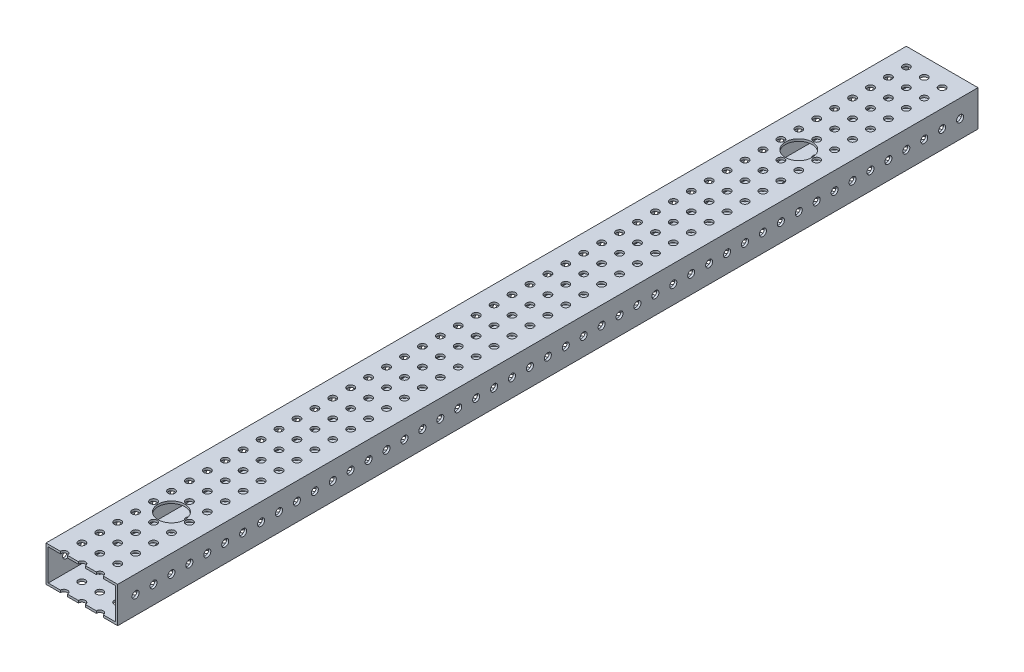
from build123d import *

# Parameters (mm, degrees)
SKETCH1_W           = 50.8
SKETCH1_H           = 25.4
SKETCH1_W_2         = 47.625
SKETCH1_H_2         = 22.225
BOSS_EXTRUDE1_DEPTH = 609.6
SKETCH2_R           = 2.4892
CUT_EXTRUDE1_DEPTH  = 51.8
SKETCH4_R           = 2.4892
CUT_EXTRUDE3_DEPTH  = 26.4
SKETCH3_R           = 9.525
CUT_EXTRUDE2_DEPTH  = 26.4


with BuildPart() as part:
    # Sketch1 → Boss-Extrude1 (new body)
    with BuildSketch(Plane.XY):
        with Locations((25.4, 12.7)):
            Rectangle(SKETCH1_W, SKETCH1_H)
        with Locations((25.4, 12.7)):
            Rectangle(SKETCH1_W_2, SKETCH1_H_2, mode=Mode.SUBTRACT)
    extrude(amount=BOSS_EXTRUDE1_DEPTH)

    # Sketch2 → Cut-Extrude1 (cut, through all)
    with BuildSketch(Plane(origin=(50.8, 0, 0), x_dir=(0, 0, -1), z_dir=(1, 0, 0))):
        with Locations((-596.9, 12.7)):
            Circle(SKETCH2_R)
        with Locations((-584.2, 12.7)):
            Circle(SKETCH2_R)
        with Locations((-571.5, 12.7)):
            Circle(SKETCH2_R)
        with Locations((-558.8, 12.7)):
            Circle(SKETCH2_R)
        with Locations((-546.1, 12.7)):
            Circle(SKETCH2_R)
        with Locations((-533.4, 12.7)):
            Circle(SKETCH2_R)
        with Locations((-520.7, 12.7)):
            Circle(SKETCH2_R)
        with Locations((-508, 12.7)):
            Circle(SKETCH2_R)
        with Locations((-495.3, 12.7)):
            Circle(SKETCH2_R)
        with Locations((-482.6, 12.7)):
            Circle(SKETCH2_R)
        with Locations((-469.9, 12.7)):
            Circle(SKETCH2_R)
        with Locations((-457.2, 12.7)):
            Circle(SKETCH2_R)
        with Locations((-444.5, 12.7)):
            Circle(SKETCH2_R)
        with Locations((-431.8, 12.7)):
            Circle(SKETCH2_R)
        with Locations((-419.1, 12.7)):
            Circle(SKETCH2_R)
        with Locations((-406.4, 12.7)):
            Circle(SKETCH2_R)
        with Locations((-393.7, 12.7)):
            Circle(SKETCH2_R)
        with Locations((-381, 12.7)):
            Circle(SKETCH2_R)
        with Locations((-368.3, 12.7)):
            Circle(SKETCH2_R)
        with Locations((-355.6, 12.7)):
            Circle(SKETCH2_R)
        with Locations((-342.9, 12.7)):
            Circle(SKETCH2_R)
        with Locations((-330.2, 12.7)):
            Circle(SKETCH2_R)
        with Locations((-317.5, 12.7)):
            Circle(SKETCH2_R)
        with Locations((-304.8, 12.7)):
            Circle(SKETCH2_R)
        with Locations((-292.1, 12.7)):
            Circle(SKETCH2_R)
        with Locations((-279.4, 12.7)):
            Circle(SKETCH2_R)
        with Locations((-266.7, 12.7)):
            Circle(SKETCH2_R)
        with Locations((-254, 12.7)):
            Circle(SKETCH2_R)
        with Locations((-241.3, 12.7)):
            Circle(SKETCH2_R)
        with Locations((-228.6, 12.7)):
            Circle(SKETCH2_R)
        with Locations((-215.9, 12.7)):
            Circle(SKETCH2_R)
        with Locations((-203.2, 12.7)):
            Circle(SKETCH2_R)
        with Locations((-190.5, 12.7)):
            Circle(SKETCH2_R)
        with Locations((-177.8, 12.7)):
            Circle(SKETCH2_R)
        with Locations((-165.1, 12.7)):
            Circle(SKETCH2_R)
        with Locations((-152.4, 12.7)):
            Circle(SKETCH2_R)
        with Locations((-139.7, 12.7)):
            Circle(SKETCH2_R)
        with Locations((-127, 12.7)):
            Circle(SKETCH2_R)
        with Locations((-114.3, 12.7)):
            Circle(SKETCH2_R)
        with Locations((-101.6, 12.7)):
            Circle(SKETCH2_R)
        with Locations((-88.9, 12.7)):
            Circle(SKETCH2_R)
        with Locations((-76.2, 12.7)):
            Circle(SKETCH2_R)
        with Locations((-63.5, 12.7)):
            Circle(SKETCH2_R)
        with Locations((-50.8, 12.7)):
            Circle(SKETCH2_R)
        with Locations((-38.1, 12.7)):
            Circle(SKETCH2_R)
        with Locations((-25.4, 12.7)):
            Circle(SKETCH2_R)
        with Locations((-12.7, 12.7)):
            Circle(SKETCH2_R)
    extrude(amount=-CUT_EXTRUDE1_DEPTH, mode=Mode.SUBTRACT)

    # Sketch4 → Cut-Extrude3 (cut, through all)
    with BuildSketch(Plane(origin=(0, 25.4, 0), x_dir=(1, 0, 0), z_dir=(0, 1, 0))):
        with Locations((12.7, -12.7)):
            Circle(SKETCH4_R)
        with Locations((25.4, -12.7)):
            Circle(SKETCH4_R)
        with Locations((38.1, -12.7)):
            Circle(SKETCH4_R)
        with Locations((25.4, -25.4)):
            Circle(SKETCH4_R)
        with Locations((38.1, -25.4)):
            Circle(SKETCH4_R)
        with Locations((25.4, -38.1)):
            Circle(SKETCH4_R)
        with Locations((38.1, -38.1)):
            Circle(SKETCH4_R)
        with Locations((25.4, -50.8)):
            Circle(SKETCH4_R)
        with Locations((38.1, -50.8)):
            Circle(SKETCH4_R)
        with Locations((25.4, -63.5)):
            Circle(SKETCH4_R)
        with Locations((38.1, -63.5)):
            Circle(SKETCH4_R)
        with Locations((25.4, -76.2)):
            Circle(SKETCH4_R)
        with Locations((38.1, -76.2)):
            Circle(SKETCH4_R)
        with Locations((25.4, -88.9)):
            Circle(SKETCH4_R)
        with Locations((38.1, -88.9)):
            Circle(SKETCH4_R)
        with Locations((25.4, -101.6)):
            Circle(SKETCH4_R)
        with Locations((38.1, -101.6)):
            Circle(SKETCH4_R)
        with Locations((25.4, -114.3)):
            Circle(SKETCH4_R)
        with Locations((38.1, -114.3)):
            Circle(SKETCH4_R)
        with Locations((25.4, -127)):
            Circle(SKETCH4_R)
        with Locations((38.1, -127)):
            Circle(SKETCH4_R)
        with Locations((25.4, -139.7)):
            Circle(SKETCH4_R)
        with Locations((38.1, -139.7)):
            Circle(SKETCH4_R)
        with Locations((25.4, -152.4)):
            Circle(SKETCH4_R)
        with Locations((38.1, -152.4)):
            Circle(SKETCH4_R)
        with Locations((25.4, -165.1)):
            Circle(SKETCH4_R)
        with Locations((38.1, -165.1)):
            Circle(SKETCH4_R)
        with Locations((25.4, -177.8)):
            Circle(SKETCH4_R)
        with Locations((38.1, -177.8)):
            Circle(SKETCH4_R)
        with Locations((25.4, -190.5)):
            Circle(SKETCH4_R)
        with Locations((38.1, -190.5)):
            Circle(SKETCH4_R)
        with Locations((25.4, -203.2)):
            Circle(SKETCH4_R)
        with Locations((38.1, -203.2)):
            Circle(SKETCH4_R)
        with Locations((25.4, -215.9)):
            Circle(SKETCH4_R)
        with Locations((38.1, -215.9)):
            Circle(SKETCH4_R)
        with Locations((25.4, -228.6)):
            Circle(SKETCH4_R)
        with Locations((38.1, -228.6)):
            Circle(SKETCH4_R)
        with Locations((25.4, -241.3)):
            Circle(SKETCH4_R)
        with Locations((38.1, -241.3)):
            Circle(SKETCH4_R)
        with Locations((25.4, -254)):
            Circle(SKETCH4_R)
        with Locations((38.1, -254)):
            Circle(SKETCH4_R)
        with Locations((25.4, -266.7)):
            Circle(SKETCH4_R)
        with Locations((38.1, -266.7)):
            Circle(SKETCH4_R)
        with Locations((25.4, -279.4)):
            Circle(SKETCH4_R)
        with Locations((38.1, -279.4)):
            Circle(SKETCH4_R)
        with Locations((25.4, -292.1)):
            Circle(SKETCH4_R)
        with Locations((38.1, -292.1)):
            Circle(SKETCH4_R)
        with Locations((25.4, -304.8)):
            Circle(SKETCH4_R)
        with Locations((38.1, -304.8)):
            Circle(SKETCH4_R)
        with Locations((25.4, -317.5)):
            Circle(SKETCH4_R)
        with Locations((38.1, -317.5)):
            Circle(SKETCH4_R)
        with Locations((25.4, -330.2)):
            Circle(SKETCH4_R)
        with Locations((38.1, -330.2)):
            Circle(SKETCH4_R)
        with Locations((25.4, -342.9)):
            Circle(SKETCH4_R)
        with Locations((38.1, -342.9)):
            Circle(SKETCH4_R)
        with Locations((25.4, -355.6)):
            Circle(SKETCH4_R)
        with Locations((38.1, -355.6)):
            Circle(SKETCH4_R)
        with Locations((25.4, -368.3)):
            Circle(SKETCH4_R)
        with Locations((38.1, -368.3)):
            Circle(SKETCH4_R)
        with Locations((25.4, -381)):
            Circle(SKETCH4_R)
        with Locations((38.1, -381)):
            Circle(SKETCH4_R)
        with Locations((25.4, -393.7)):
            Circle(SKETCH4_R)
        with Locations((38.1, -393.7)):
            Circle(SKETCH4_R)
        with Locations((25.4, -406.4)):
            Circle(SKETCH4_R)
        with Locations((38.1, -406.4)):
            Circle(SKETCH4_R)
        with Locations((25.4, -419.1)):
            Circle(SKETCH4_R)
        with Locations((38.1, -419.1)):
            Circle(SKETCH4_R)
        with Locations((25.4, -431.8)):
            Circle(SKETCH4_R)
        with Locations((38.1, -431.8)):
            Circle(SKETCH4_R)
        with Locations((25.4, -444.5)):
            Circle(SKETCH4_R)
        with Locations((38.1, -444.5)):
            Circle(SKETCH4_R)
        with Locations((25.4, -457.2)):
            Circle(SKETCH4_R)
        with Locations((38.1, -457.2)):
            Circle(SKETCH4_R)
        with Locations((25.4, -469.9)):
            Circle(SKETCH4_R)
        with Locations((38.1, -469.9)):
            Circle(SKETCH4_R)
        with Locations((25.4, -482.6)):
            Circle(SKETCH4_R)
        with Locations((38.1, -482.6)):
            Circle(SKETCH4_R)
        with Locations((25.4, -495.3)):
            Circle(SKETCH4_R)
        with Locations((38.1, -495.3)):
            Circle(SKETCH4_R)
        with Locations((25.4, -508)):
            Circle(SKETCH4_R)
        with Locations((38.1, -508)):
            Circle(SKETCH4_R)
        with Locations((25.4, -520.7)):
            Circle(SKETCH4_R)
        with Locations((38.1, -520.7)):
            Circle(SKETCH4_R)
        with Locations((25.4, -533.4)):
            Circle(SKETCH4_R)
        with Locations((38.1, -533.4)):
            Circle(SKETCH4_R)
        with Locations((25.4, -546.1)):
            Circle(SKETCH4_R)
        with Locations((38.1, -546.1)):
            Circle(SKETCH4_R)
        with Locations((25.4, -558.8)):
            Circle(SKETCH4_R)
        with Locations((38.1, -558.8)):
            Circle(SKETCH4_R)
        with Locations((25.4, -571.5)):
            Circle(SKETCH4_R)
        with Locations((38.1, -571.5)):
            Circle(SKETCH4_R)
        with Locations((25.4, -584.2)):
            Circle(SKETCH4_R)
        with Locations((38.1, -584.2)):
            Circle(SKETCH4_R)
        with Locations((25.4, -596.9)):
            Circle(SKETCH4_R)
        with Locations((38.1, -596.9)):
            Circle(SKETCH4_R)
        with Locations((25.4, -609.6)):
            Circle(SKETCH4_R)
        with Locations((38.1, -609.6)):
            Circle(SKETCH4_R)
        with Locations((12.7, -25.4)):
            Circle(SKETCH4_R)
        with Locations((12.7, -38.1)):
            Circle(SKETCH4_R)
        with Locations((12.7, -50.8)):
            Circle(SKETCH4_R)
        with Locations((12.7, -63.5)):
            Circle(SKETCH4_R)
        with Locations((12.7, -76.2)):
            Circle(SKETCH4_R)
        with Locations((12.7, -88.9)):
            Circle(SKETCH4_R)
        with Locations((12.7, -101.6)):
            Circle(SKETCH4_R)
        with Locations((12.7, -114.3)):
            Circle(SKETCH4_R)
        with Locations((12.7, -127)):
            Circle(SKETCH4_R)
        with Locations((12.7, -139.7)):
            Circle(SKETCH4_R)
        with Locations((12.7, -152.4)):
            Circle(SKETCH4_R)
        with Locations((12.7, -165.1)):
            Circle(SKETCH4_R)
        with Locations((12.7, -177.8)):
            Circle(SKETCH4_R)
        with Locations((12.7, -190.5)):
            Circle(SKETCH4_R)
        with Locations((12.7, -203.2)):
            Circle(SKETCH4_R)
        with Locations((12.7, -215.9)):
            Circle(SKETCH4_R)
        with Locations((12.7, -228.6)):
            Circle(SKETCH4_R)
        with Locations((12.7, -241.3)):
            Circle(SKETCH4_R)
        with Locations((12.7, -254)):
            Circle(SKETCH4_R)
        with Locations((12.7, -266.7)):
            Circle(SKETCH4_R)
        with Locations((12.7, -279.4)):
            Circle(SKETCH4_R)
        with Locations((12.7, -292.1)):
            Circle(SKETCH4_R)
        with Locations((12.7, -304.8)):
            Circle(SKETCH4_R)
        with Locations((12.7, -317.5)):
            Circle(SKETCH4_R)
        with Locations((12.7, -330.2)):
            Circle(SKETCH4_R)
        with Locations((12.7, -342.9)):
            Circle(SKETCH4_R)
        with Locations((12.7, -355.6)):
            Circle(SKETCH4_R)
        with Locations((12.7, -368.3)):
            Circle(SKETCH4_R)
        with Locations((12.7, -381)):
            Circle(SKETCH4_R)
        with Locations((12.7, -393.7)):
            Circle(SKETCH4_R)
        with Locations((12.7, -406.4)):
            Circle(SKETCH4_R)
        with Locations((12.7, -419.1)):
            Circle(SKETCH4_R)
        with Locations((12.7, -431.8)):
            Circle(SKETCH4_R)
        with Locations((12.7, -444.5)):
            Circle(SKETCH4_R)
        with Locations((12.7, -457.2)):
            Circle(SKETCH4_R)
        with Locations((12.7, -469.9)):
            Circle(SKETCH4_R)
        with Locations((12.7, -482.6)):
            Circle(SKETCH4_R)
        with Locations((12.7, -495.3)):
            Circle(SKETCH4_R)
        with Locations((12.7, -508)):
            Circle(SKETCH4_R)
        with Locations((12.7, -520.7)):
            Circle(SKETCH4_R)
        with Locations((12.7, -533.4)):
            Circle(SKETCH4_R)
        with Locations((12.7, -546.1)):
            Circle(SKETCH4_R)
        with Locations((12.7, -558.8)):
            Circle(SKETCH4_R)
        with Locations((12.7, -571.5)):
            Circle(SKETCH4_R)
        with Locations((12.7, -584.2)):
            Circle(SKETCH4_R)
        with Locations((12.7, -596.9)):
            Circle(SKETCH4_R)
        with Locations((12.7, -609.6)):
            Circle(SKETCH4_R)
    extrude(amount=-CUT_EXTRUDE3_DEPTH, mode=Mode.SUBTRACT)

    # Sketch3 → Cut-Extrude2 (cut, through all)
    with BuildSketch(Plane.XZ):
        with Locations((25.4, 546.1)):
            Circle(SKETCH3_R)
        with Locations((25.4, 101.6)):
            Circle(SKETCH3_R)
    extrude(amount=-CUT_EXTRUDE2_DEPTH, mode=Mode.SUBTRACT)


solid = part.part
